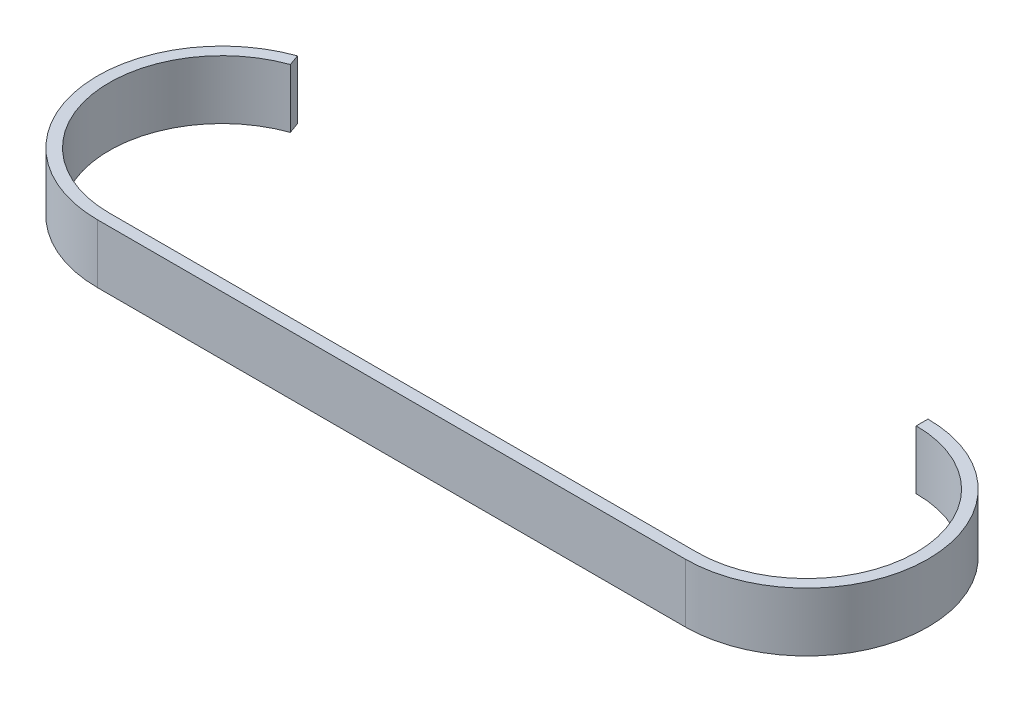
from build123d import *

# Parameters (mm, degrees)
EXTRUDE_THIN1_DEPTH = 12.7


with BuildPart() as part:
    # Sketch1 → Extrude-Thin1 (new body)
    with BuildSketch(Plane(origin=(0, 0, 0), x_dir=(1, 0, 0), z_dir=(0, 1, 0))):
        with BuildLine():
            ThreePointArc((-8.201608063, 47.335515762), (-24.020394602, 20.216381636), (0, 0))
            Line((0, 0), (127, 0))
            ThreePointArc((127, 0), (150.667757881, 23.667757881), (127, 47.335515762))
            Line((127, 47.335515762), (127, 49.875515762))
            ThreePointArc((127, 49.875515762), (153.207757881, 23.667757881), (127, -2.54))
            Line((127, -2.54), (0, -2.54))
            ThreePointArc((0, -2.54), (-26.52310557, 19.782748367), (-9.056142503, 49.727454493))
            Line((-9.056142503, 49.727454493), (-8.201608063, 47.335515762))
        make_face()
    extrude(amount=EXTRUDE_THIN1_DEPTH)


solid = part.part
